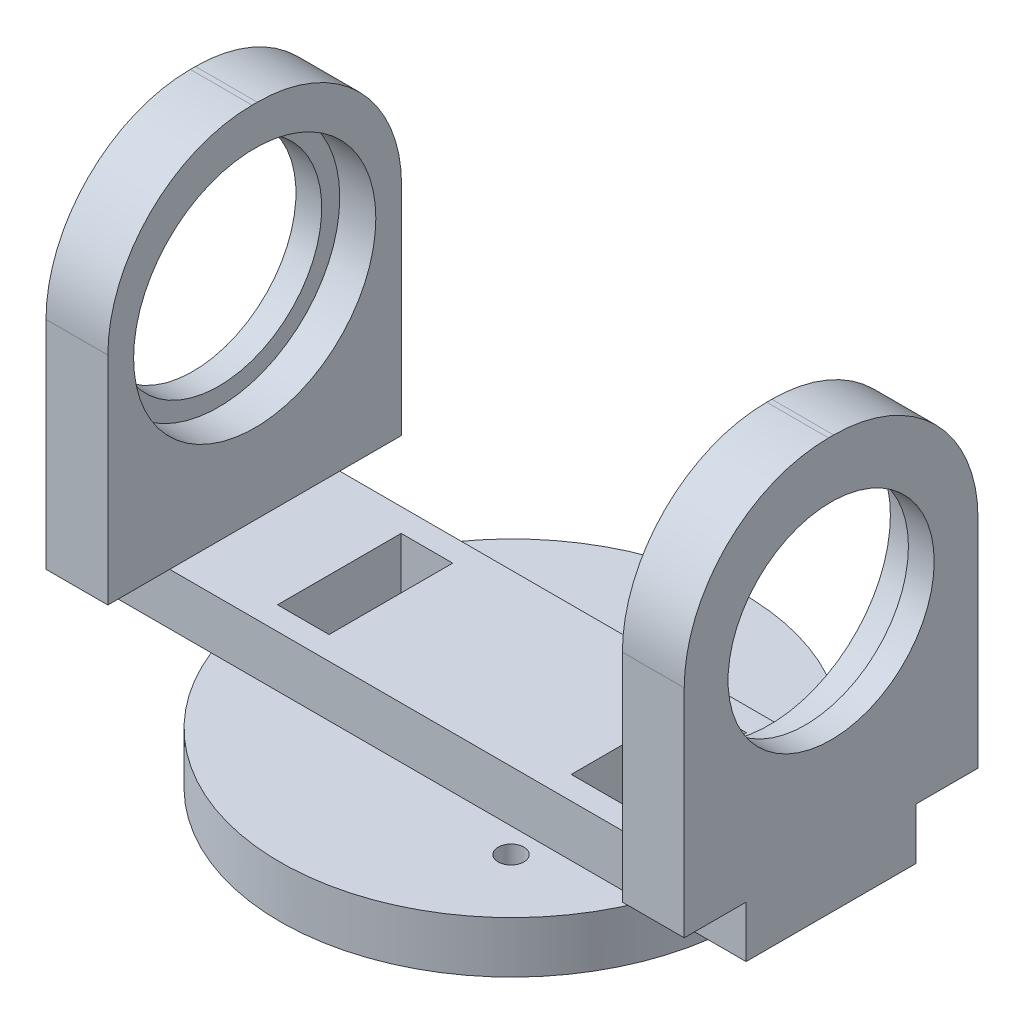
from build123d import *

# Parameters (mm, degrees)
SKETCH1_W           = 123.84
SKETCH1_H           = 33
BOSS_EXTRUDE1_DEPTH = 10
SKETCH2_W           = 12
SKETCH2_H           = 57
BOSS_EXTRUDE2_DEPTH = 70
SKETCH3_R           = 23.5
CUT_EXTRUDE1_DEPTH  = 124.84
SKETCH10_R          = 45
BOSS_EXTRUDE5_DEPTH = 10
SKETCH9_R           = 2.5
SKETCH9_W           = 10
SKETCH9_H           = 24
CUT_EXTRUDE3_DEPTH  = 21
FILLET1_R           = 28
SKETCH11_R          = 23.5
SKETCH11_R_2        = 20
BOSS_EXTRUDE6_DEPTH = 5
SKETCH12_R          = 23.5
SKETCH12_R_2        = 20
BOSS_EXTRUDE7_DEPTH = 5


with BuildPart() as part:
    # Sketch1 → Boss-Extrude1 (new body)
    with BuildSketch(Plane(origin=(0, 0, 0), x_dir=(1, 0, 0), z_dir=(0, 1, 0))):
        Rectangle(SKETCH1_W, SKETCH1_H)
    extrude(amount=BOSS_EXTRUDE1_DEPTH)

    # Sketch2 → Boss-Extrude2 (add)
    with BuildSketch(Plane(origin=(0, 10, 0), x_dir=(1, 0, 0), z_dir=(0, 1, 0))):
        with Locations((-55.92, 0)):
            Rectangle(SKETCH2_W, SKETCH2_H)
        with Locations((55.92, 0)):
            Rectangle(SKETCH2_W, SKETCH2_H)
    extrude(amount=BOSS_EXTRUDE2_DEPTH)

    # Sketch3 → Cut-Extrude1 (cut, through all)
    with BuildSketch(Plane(origin=(61.92, 0, 0), x_dir=(0, 0, -1), z_dir=(1, 0, 0))):
        with Locations((0, 49)):
            Circle(SKETCH3_R)
    extrude(amount=-CUT_EXTRUDE1_DEPTH, mode=Mode.SUBTRACT)

    # Sketch10 → Boss-Extrude5 (add)
    with BuildSketch(Plane.XZ):
        Circle(SKETCH10_R)
    extrude(amount=BOSS_EXTRUDE5_DEPTH)

    # Sketch9 → Cut-Extrude3 (cut, through all)
    with BuildSketch(Plane(origin=(0, 10, 0), x_dir=(1, 0, 0), z_dir=(0, 1, 0))):
        with Locations((21.118713953, -21.307273899)):
            Circle(SKETCH9_R)
        with Locations((21.307273899, 21.118713953)):
            Circle(SKETCH9_R)
        with Locations((-21.118713953, 21.307273899)):
            Circle(SKETCH9_R)
        with Locations((-28.5, 0)):
            Rectangle(SKETCH9_W, SKETCH9_H)
        with Locations((28.5, 0)):
            Rectangle(SKETCH9_W, SKETCH9_H)
    extrude(amount=-CUT_EXTRUDE3_DEPTH, mode=Mode.SUBTRACT)

    # Fillet1
    fillet1_edges = [part.edges().sort_by_distance(p)[0] for p in [
        (-55.92, 80, 28.5),
        (-55.92, 80, -28.5),
        (55.92, 80, -28.5),
        (55.92, 80, 28.5),
    ]]
    fillet(fillet1_edges, radius=FILLET1_R)

    # Sketch11 → Boss-Extrude6 (add)
    with BuildSketch(Plane(origin=(61.92, 0, 0), x_dir=(0, 0, -1), z_dir=(1, 0, 0))):
        with Locations((0, 49)):
            Circle(SKETCH11_R)
        with Locations((0, 49)):
            Circle(SKETCH11_R_2, mode=Mode.SUBTRACT)
    extrude(amount=-BOSS_EXTRUDE6_DEPTH)

    # Sketch12 → Boss-Extrude7 (add)
    with BuildSketch(Plane.ZY.offset(61.92)):
        with Locations((0, 49)):
            Circle(SKETCH12_R)
        with Locations((0, 49)):
            Circle(SKETCH12_R_2, mode=Mode.SUBTRACT)
    extrude(amount=-BOSS_EXTRUDE7_DEPTH)


solid = part.part
